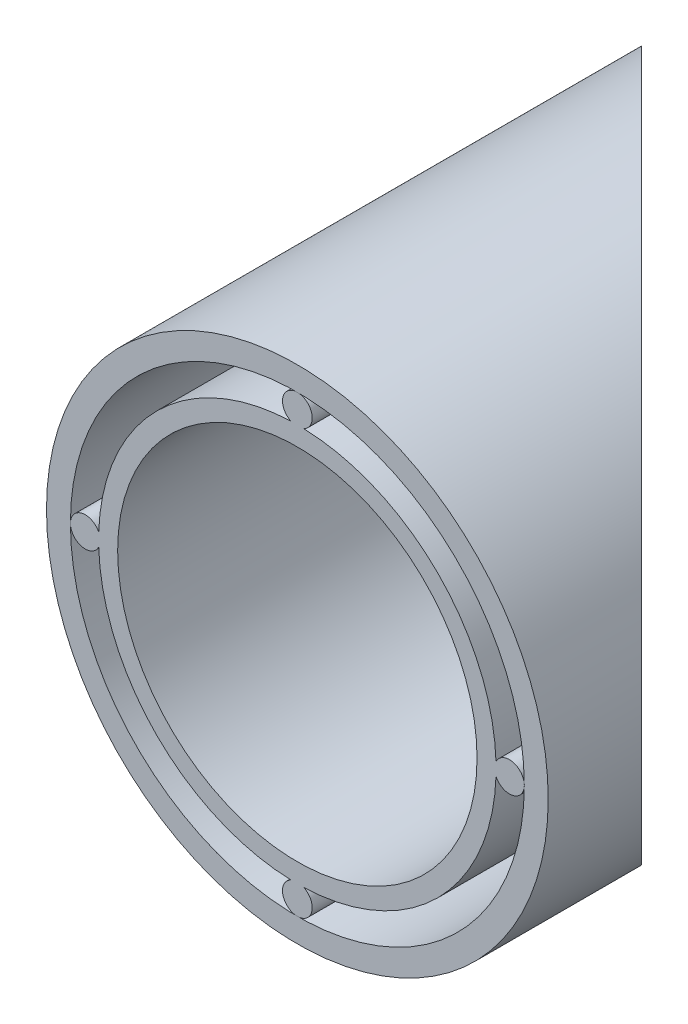
from build123d import *

# Parameters (mm, degrees)
SKETCH1_R           = 21.08
SKETCH1_R_2         = 19.07
BOSS_EXTRUDE1_DEPTH = 50
SKETCH3_R           = 16.7
SKETCH3_R_2         = 15.1
BOSS_EXTRUDE2_DEPTH = 50
SKETCH4_R           = 1.25
BOSS_EXTRUDE3_DEPTH = 50
CUT_EXTRUDE1_DEPTH  = 76.5


with BuildPart() as part:
    # Sketch1 → Boss-Extrude1 (new body)
    with BuildSketch(Plane.XY):
        Circle(SKETCH1_R)
        Circle(SKETCH1_R_2, mode=Mode.SUBTRACT)
    extrude(amount=-BOSS_EXTRUDE1_DEPTH)


with BuildPart() as body_2:
    # Sketch3 → Boss-Extrude2 (new body)
    with BuildSketch(Plane.XY):
        Circle(SKETCH3_R)
        Circle(SKETCH3_R_2, mode=Mode.SUBTRACT)
    extrude(amount=-BOSS_EXTRUDE2_DEPTH)

    # Sketch4 → Boss-Extrude3 (add)
    with BuildSketch(Plane.XY):
        with Locations((0, -17.82)):
            Circle(SKETCH4_R)
        with Locations((-17.82, 0)):
            Circle(SKETCH4_R)
        with Locations((0, 17.82)):
            Circle(SKETCH4_R)
        with Locations((17.82, 0)):
            Circle(SKETCH4_R)
    extrude(amount=-BOSS_EXTRUDE3_DEPTH)


with BuildPart() as cut_extrude1_tool:
    # Sketch2 → Cut-Extrude1 (new body, symmetric)
    with BuildSketch(Plane(origin=(0, 0, 0), x_dir=(1, 0, 0), z_dir=(0, 1, 0))):
        Polygon((-21.08, 50), (21.08, 7.84), (21.08, 50), align=None)
    extrude(amount=CUT_EXTRUDE1_DEPTH, both=True)


with BuildPart() as part_1:
    add(part.part)

    # Cut-Extrude1: cut by cut_extrude1_tool
    add(cut_extrude1_tool.part, mode=Mode.SUBTRACT)


with BuildPart() as body_2_1:
    add(body_2.part)

    # Cut-Extrude1: cut by cut_extrude1_tool
    add(cut_extrude1_tool.part, mode=Mode.SUBTRACT)


solid = Compound([part_1.part, body_2_1.part])
